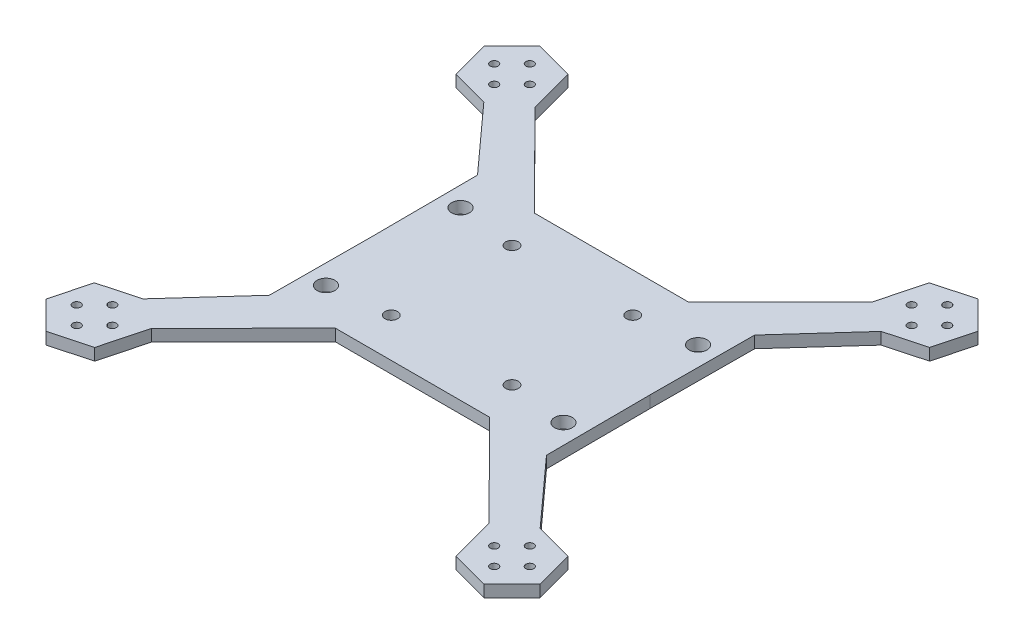
from build123d import *

# Parameters (mm, degrees)
SKETCH1_R           = 1
SKETCH1_R_2         = 2.25
SKETCH1_R_3         = 1.6
BOSS_EXTRUDE1_DEPTH = 3


with BuildPart() as part:
    # Sketch1 → Boss-Extrude1 (new body)
    with BuildSketch(Plane(origin=(0, 0, 0), x_dir=(1, 0, 0), z_dir=(0, 1, 0))):
        Polygon((43.076410298, 50.123925917), (42.618597625, 48.402115535), (19.4637773, 25.158118275), (-19.4637773, 25.158118275), (-42.618597625, 48.402115535), (-45.64603124, 59.788140743), (-55.300297258, 62.394891143), (-62.384942335, 55.337426715), (-59.815321393, 45.673211889), (-50.185022628, 43.072932893), (-35, 26.288270568), (-34.873, 0), (-35, -26.288270568), (-50.185022628, -43.072932893), (-59.815321393, -45.673211889), (-62.384942335, -55.337426715), (-55.300297258, -62.394891143), (-45.64603124, -59.788140743), (-42.618597625, -48.402115535), (-19.4637773, -25.158118275), (19.4637773, -25.158118275), (42.618597625, -48.402115535), (45.64603124, -59.788140743), (55.300297258, -62.394891143), (62.384942335, -55.337426715), (59.815321393, -45.673211889), (50.185022628, -43.072932893), (35, -26.288270568), (34.873, 0), (35, 26.288270568), (50.185022628, 43.072932893), (59.815321393, 45.673211889), (62.384942335, 55.337426715), (55.300297258, 62.394891143), (45.64603124, 59.788140743), align=None)
        with Locations((-52.730676316, -57.230676316)):
            Circle(SKETCH1_R, mode=Mode.SUBTRACT)
        with Locations((-57.230676316, -52.730676316)):
            Circle(SKETCH1_R, mode=Mode.SUBTRACT)
        with Locations((-48.230676316, -52.730676316)):
            Circle(SKETCH1_R, mode=Mode.SUBTRACT)
        with Locations((-52.730676316, -48.230676316)):
            Circle(SKETCH1_R, mode=Mode.SUBTRACT)
        with Locations((-30, -17)):
            Circle(SKETCH1_R_2, mode=Mode.SUBTRACT)
        with Locations((-15.25, -15.25)):
            Circle(SKETCH1_R_3, mode=Mode.SUBTRACT)
        with Locations((52.730676316, -57.230676316)):
            Circle(SKETCH1_R, mode=Mode.SUBTRACT)
        with Locations((48.230676316, -52.730676316)):
            Circle(SKETCH1_R, mode=Mode.SUBTRACT)
        with Locations((52.730676316, -48.230676316)):
            Circle(SKETCH1_R, mode=Mode.SUBTRACT)
        with Locations((57.230676316, -52.730676316)):
            Circle(SKETCH1_R, mode=Mode.SUBTRACT)
        with Locations((30, -17)):
            Circle(SKETCH1_R_2, mode=Mode.SUBTRACT)
        with Locations((15.25, -15.25)):
            Circle(SKETCH1_R_3, mode=Mode.SUBTRACT)
        with Locations((-15.25, 15.25)):
            Circle(SKETCH1_R_3, mode=Mode.SUBTRACT)
        with Locations((-30, 17)):
            Circle(SKETCH1_R_2, mode=Mode.SUBTRACT)
        with Locations((-57.230676316, 52.730676316)):
            Circle(SKETCH1_R, mode=Mode.SUBTRACT)
        with Locations((-52.730676316, 48.230676316)):
            Circle(SKETCH1_R, mode=Mode.SUBTRACT)
        with Locations((-48.230676316, 52.730676316)):
            Circle(SKETCH1_R, mode=Mode.SUBTRACT)
        with Locations((-52.730676316, 57.230676316)):
            Circle(SKETCH1_R, mode=Mode.SUBTRACT)
        with Locations((15.25, 15.25)):
            Circle(SKETCH1_R_3, mode=Mode.SUBTRACT)
        with Locations((30, 17)):
            Circle(SKETCH1_R_2, mode=Mode.SUBTRACT)
        with Locations((52.730676316, 48.230676316)):
            Circle(SKETCH1_R, mode=Mode.SUBTRACT)
        with Locations((48.230676316, 52.730676316)):
            Circle(SKETCH1_R, mode=Mode.SUBTRACT)
        with Locations((57.230676316, 52.730676316)):
            Circle(SKETCH1_R, mode=Mode.SUBTRACT)
        with Locations((52.730676316, 57.230676316)):
            Circle(SKETCH1_R, mode=Mode.SUBTRACT)
    extrude(amount=BOSS_EXTRUDE1_DEPTH)


solid = part.part
